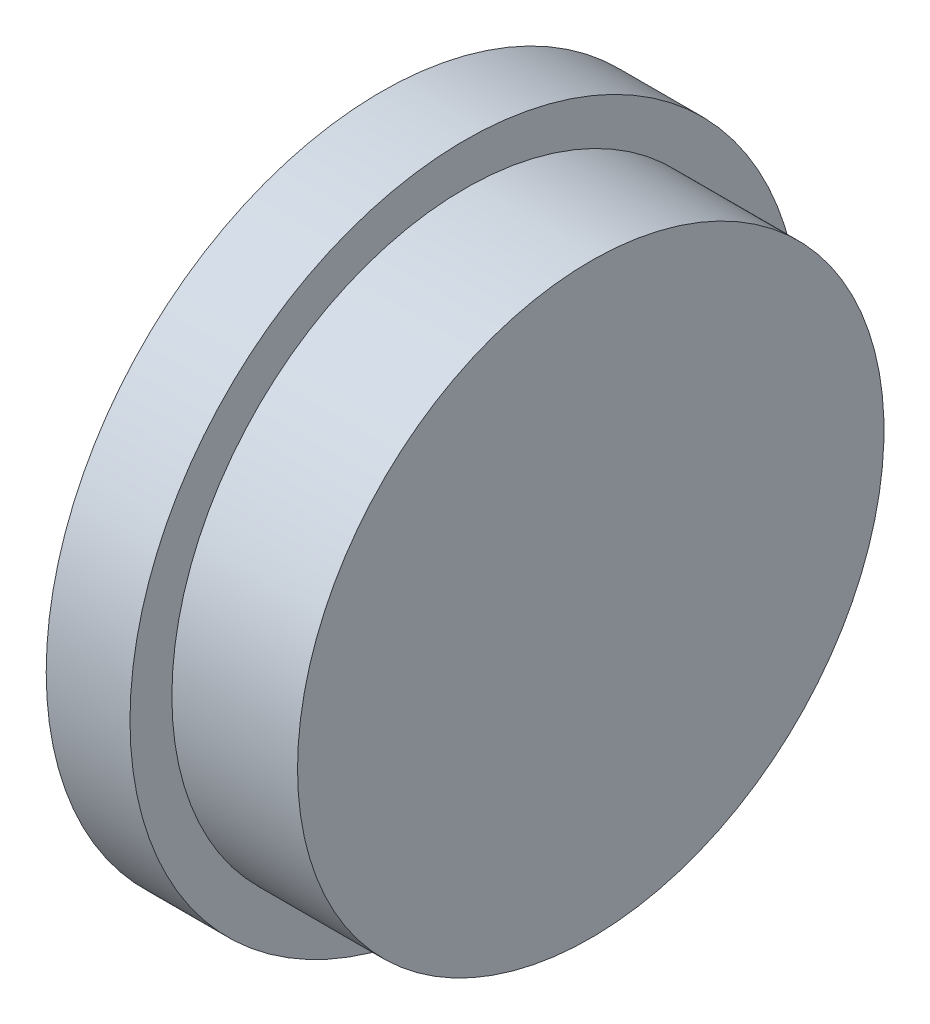
from build123d import *


with BuildPart() as part:
    # Esquisse2 → Révolution1 (revolve)
    with BuildSketch(Plane.XY):
        Polygon((13, 0), (13, 16), (0, 16), (0, 24), (6, 24), (6, 21), (15, 21), (15, 0), align=None)
    revolve(axis=Axis((0, 0, 0), (1, 0, 0)))


solid = part.part
